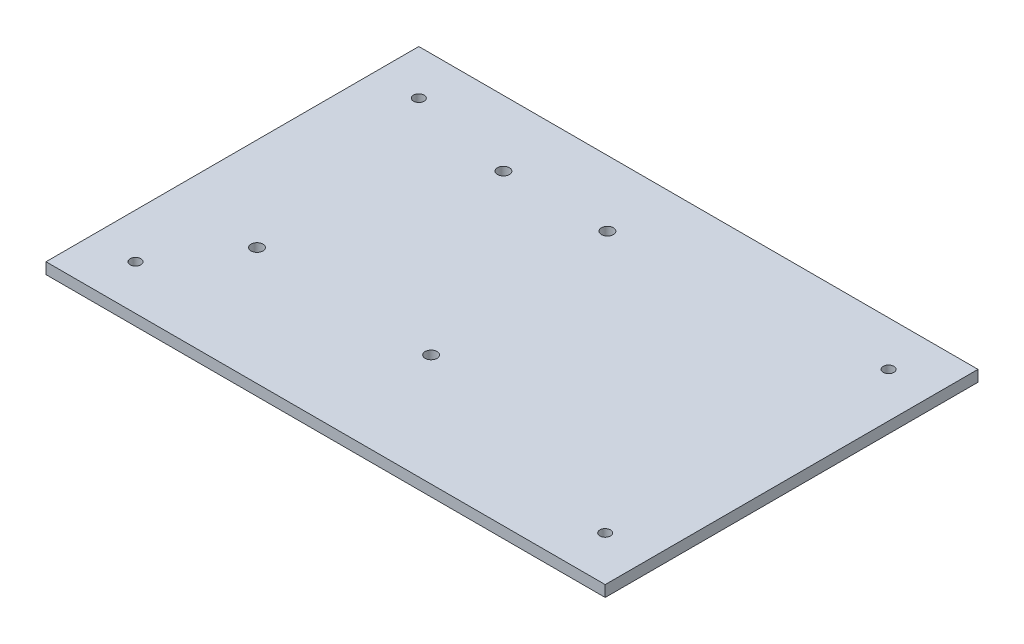
from build123d import *

# Parameters (mm, degrees)
SKETCH1_W           = 150
SKETCH1_H           = 100
BOSS_EXTRUDE1_DEPTH = 3
SKETCH2_R           = 1.425
CUT_EXTRUDE1_DEPTH  = 10
LPATTERN1_COUNT     = 2
LPATTERN1_PITCH     = 76
SKETCH5_R           = 1.6
CUT_EXTRUDE4_DEPTH  = 10
SKETCH6_R           = 1.425
CUT_EXTRUDE5_DEPTH  = 10


with BuildPart() as part:
    # Sketch1 → Boss-Extrude1 (new body)
    with BuildSketch(Plane(origin=(0, 0, 0), x_dir=(1, 0, 0), z_dir=(0, 1, 0))):
        Rectangle(SKETCH1_W, SKETCH1_H)
    extrude(amount=BOSS_EXTRUDE1_DEPTH)

    # Sketch2 → Cut-Extrude1 (cut)
    with BuildSketch(Plane(origin=(0, 3, 0), x_dir=(1, 0, 0), z_dir=(0, 1, 0))):
        with Locations((-63, 38)):
            Circle(SKETCH2_R)
    cut_extrude1 = extrude(amount=-CUT_EXTRUDE1_DEPTH, mode=Mode.SUBTRACT)

    # LPattern1: Cut-Extrude1 ×2
    with Locations(*[(0, 0, i * LPATTERN1_PITCH) for i in range(1, LPATTERN1_COUNT)]):
        add(cut_extrude1, mode=Mode.SUBTRACT)

    # Sketch5 → Cut-Extrude4 (cut)
    with BuildSketch(Plane(origin=(0, 3, 0), x_dir=(1, 0, 0), z_dir=(0, 1, 0))):
        with Locations((-34.7, 32.4)):
            Circle(SKETCH5_R)
        with Locations((-6.8, 32.4)):
            Circle(SKETCH5_R)
        with Locations((-1.7, -20)):
            Circle(SKETCH5_R)
        with Locations((-50, -18.4)):
            Circle(SKETCH5_R)
    extrude(amount=-CUT_EXTRUDE4_DEPTH, mode=Mode.SUBTRACT)

    # Sketch6 → Cut-Extrude5 (cut)
    with BuildSketch(Plane.XZ):
        with Locations((63, 38)):
            Circle(SKETCH6_R)
        with Locations((63, -38)):
            Circle(SKETCH6_R)
    extrude(amount=-CUT_EXTRUDE5_DEPTH, mode=Mode.SUBTRACT)


solid = part.part
